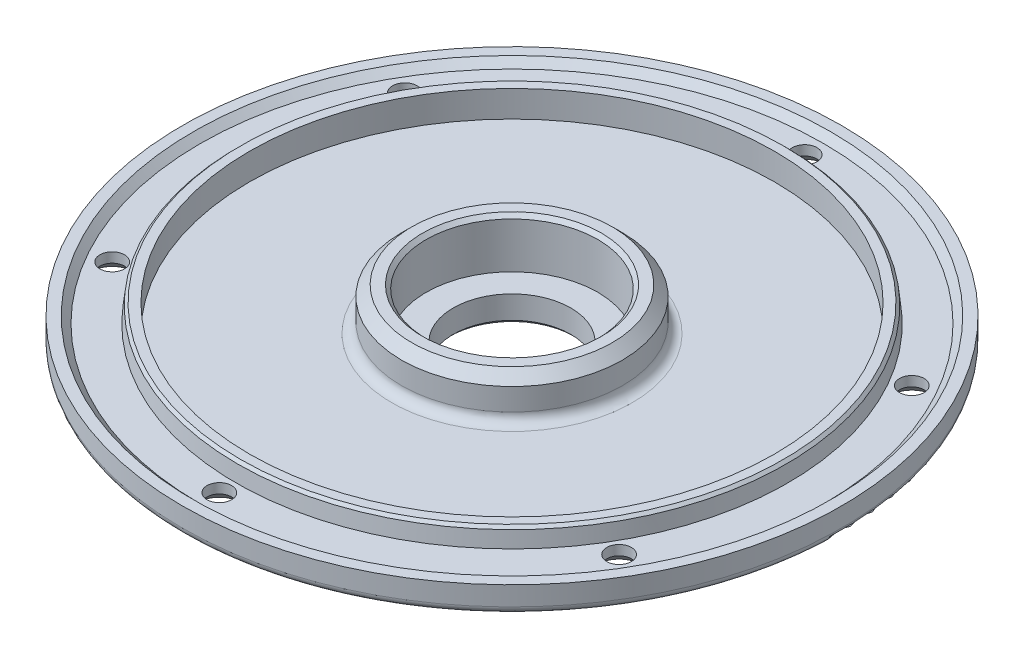
from build123d import *

# Parameters (mm, degrees)
ESQUISSE3_R                               = 2.5
ENL_V_MAT_EXTRU_1_DEPTH                   = 11.85
CHANFREIN1_SIZE                           = 2
R_P_TITION_CIRCULAIRE1_COUNT              = 6
CHANFREIN1_OF_R_P_TITION_CIRCULAIRE1_SIZE = 2


with BuildPart() as part:
    # Esquisse2 → Révolution1 (revolve)
    with BuildSketch(Plane.XY):
        with BuildLine():
            Line((-11.95, 56.6), (-17.45, 56.6))
            Line((-17.45, 56.6), (-17.45, 65.9))
            Line((-17.45, 65.9), (-18.2, 66.65))
            Line((-18.2, 66.65), (-20.4, 66.65))
            Line((-20.4, 66.65), (-22.45, 64.6))
            Line((-22.45, 64.6), (-22.45, 60.1))
            ThreePointArc((-22.45, 60.1), (-23.035786438, 58.685786438), (-24.45, 58.1))
            Line((-24.45, 58.1), (-53.35, 58.1))
            Line((-53.35, 58.1), (-53.35, 63.5))
            Line((-53.35, 63.5), (-55.2, 63.5))
            Line((-55.2, 63.5), (-55.75, 62.95))
            Line((-55.75, 62.95), (-56.1, 59.8))
            Line((-56.1, 59.8), (-63.4, 59.8))
            Line((-63.4, 59.8), (-64.8, 61.2))
            Line((-64.8, 61.2), (-67, 61.2))
            Line((-67, 61.2), (-67, 57.3))
            ThreePointArc((-67, 57.3), (-66.560660172, 56.239339828), (-65.5, 55.8))
            Line((-65.5, 55.8), (-21.9, 55.8))
            Line((-21.9, 55.8), (-15, 51.2))
            Line((-15, 51.2), (-12.7, 51.2))
            Line((-12.7, 51.2), (-11.95, 51.95))
            Line((-11.95, 51.95), (-11.95, 56.6))
        make_face()
    revolve(axis=Axis((0, 0, 0), (0, 1, 0)))

    # Esquisse3 → Enlèv. mat.-Extru.1 (cut, through all)
    with BuildSketch(Plane.XZ.offset(-55.8)):
        with Locations((0, 59.5)):
            Circle(ESQUISSE3_R)
    enl_v_mat_extru_1 = extrude(amount=-ENL_V_MAT_EXTRU_1_DEPTH, mode=Mode.SUBTRACT)

    # Chanfrein1
    chanfrein1_edges = [part.edges().sort_by_distance(p)[0] for p in [
        (-2.5, 55.8, 59.5),
    ]]
    chamfer(chanfrein1_edges, length=CHANFREIN1_SIZE)

    # Répétition circulaire1: Enlèv. mat.-Extru.1 ×6 about axis
    r_p_tition_circulaire1_axis = Axis((0, 0, 0), (0, 1, 0))
    for i in range(1, R_P_TITION_CIRCULAIRE1_COUNT):
        add(enl_v_mat_extru_1.rotate(r_p_tition_circulaire1_axis, i * 360 / R_P_TITION_CIRCULAIRE1_COUNT), mode=Mode.SUBTRACT)

    # Chanfrein1 of Répétition circulaire1
    chanfrein1_of_r_p_tition_circulaire1_edges = [part.edges().sort_by_distance(p)[0] for p in [
        (50.278511525, 55.8, 31.915063509),
        (52.778511525, 55.8, -27.584936491),
        (2.5, 55.8, -59.5),
        (-50.278511525, 55.8, -31.915063509),
        (-52.778511525, 55.8, 27.584936491),
    ]]
    chamfer(chanfrein1_of_r_p_tition_circulaire1_edges, length=CHANFREIN1_OF_R_P_TITION_CIRCULAIRE1_SIZE)


solid = part.part
